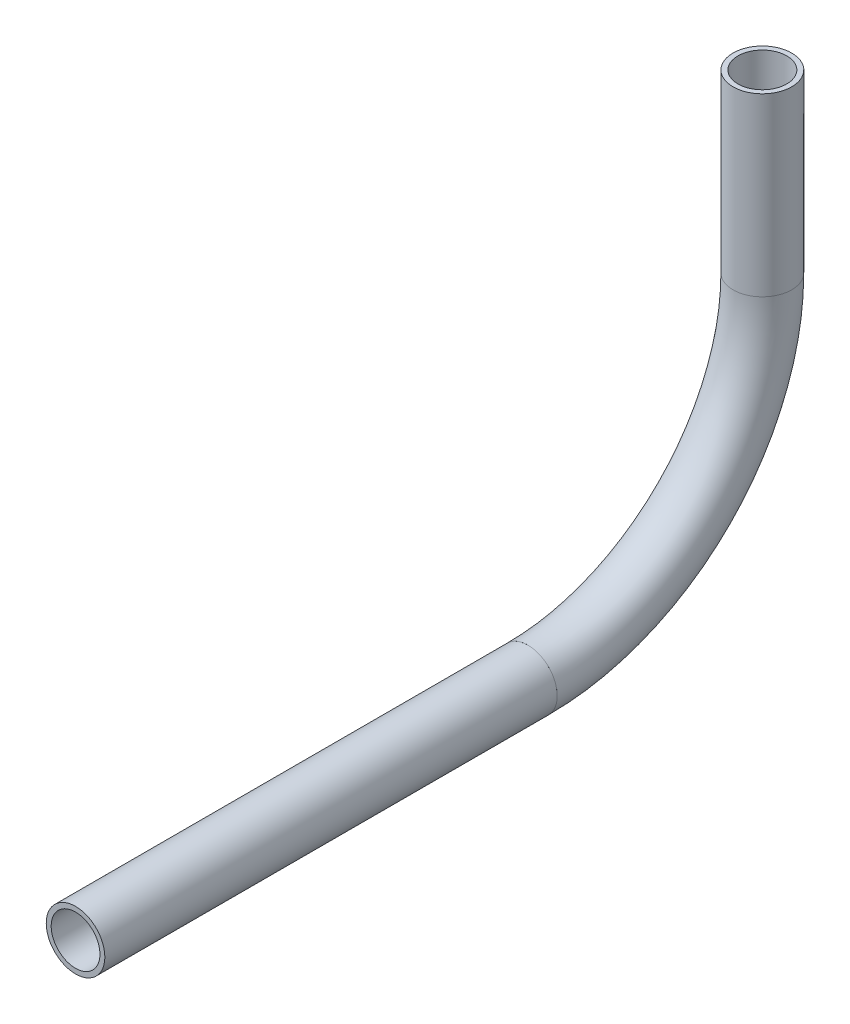
from build123d import *

# Parameters (mm, degrees)
SKETCH1_R                 = 6.35
SKETCH1_R_2               = 5.2832
PIPE_0_5_SCH_40_1_DEPTH   = 38.1
SKETCH1_ON_SEGMENT_2_R    = 6.35
SKETCH1_ON_SEGMENT_2_R_2  = 5.2832
PIPE_0_5_SCH_40_1_2_ANGLE = 90
SKETCH1_ON_SEGMENT_3_R    = 6.35
SKETCH1_ON_SEGMENT_3_R_2  = 5.2832
PIPE_0_5_SCH_40_1_3_DEPTH = 98.029336108


with BuildPart() as part:
    # Sketch1 → Pipe 0.5 SCH 40(1) (new body)
    with BuildSketch(Plane(origin=(0, -242.649158879, 278.748163938), x_dir=(0, 0, -1), z_dir=(0, -1, 0))):
        Circle(SKETCH1_R)
        Circle(SKETCH1_R_2, mode=Mode.SUBTRACT)
    extrude(amount=PIPE_0_5_SCH_40_1_DEPTH)


with BuildPart() as body_2:
    # Sketch1 on segment 2 (carried to the start of arc 2) → Pipe 0.5 SCH 40_1 2 (revolve)
    with BuildSketch(Plane(origin=(0, -280.749158879, 278.748163938), x_dir=(0, 0, -1), z_dir=(0, -1, 0))):
        Circle(SKETCH1_ON_SEGMENT_2_R)
        Circle(SKETCH1_ON_SEGMENT_2_R_2, mode=Mode.SUBTRACT)
    revolve(axis=Axis((0, -280.749158879, 329.548163938), (-1, 0, 0)), revolution_arc=PIPE_0_5_SCH_40_1_2_ANGLE)


with BuildPart() as body_3:
    # Sketch1 on segment 3 (carried to segment 3) → Pipe 0.5 SCH 40_1 3 (new body)
    with BuildSketch(Plane(origin=(0, -331.549158879, 329.548163938), x_dir=(0, -1, 0), z_dir=(0, 0, 1))):
        Circle(SKETCH1_ON_SEGMENT_3_R)
        Circle(SKETCH1_ON_SEGMENT_3_R_2, mode=Mode.SUBTRACT)
    extrude(amount=PIPE_0_5_SCH_40_1_3_DEPTH)


solid = Compound([part.part, body_2.part, body_3.part])
